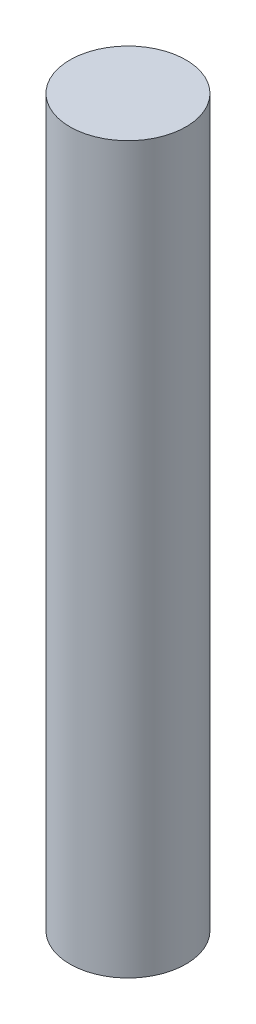
from build123d import *

# Parameters (mm, degrees)
SKETCH1_R           = 16
BOSS_EXTRUDE1_DEPTH = 200


with BuildPart() as part:
    # Sketch1 → Boss-Extrude1 (new body)
    with BuildSketch(Plane(origin=(0, 0, 0), x_dir=(1, 0, 0), z_dir=(0, 1, 0))):
        Circle(SKETCH1_R)
    extrude(amount=BOSS_EXTRUDE1_DEPTH)


solid = part.part
